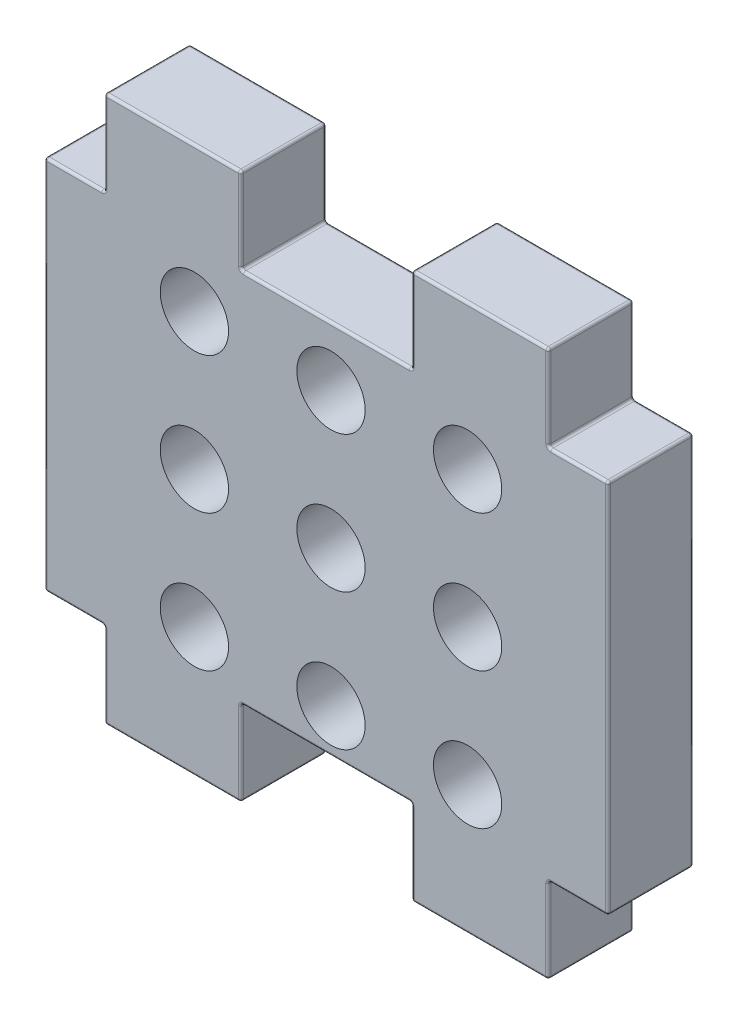
from build123d import *

# Parameters (mm, degrees)
SZKIC1_R                    = 2
SZKIC1_W                    = 8
SZKIC1_H                    = 5
DODANIE_WYCI_GNI_CIE1_DEPTH = 2.5
ZAOKR_GLENIE1_R             = 0.15


with BuildPart() as part:
    # Szkic1 → Dodanie-wyciągnięcie1 (new body, symmetric)
    with BuildSketch(Plane.XY):
        Polygon((-13, 11), (-16.5, 11), (-16.5, -11), (-13, -11), (-5, -11), (5, -11), (13, -11), (16.5, -11), (16.5, 11), (13, 11), (5, 11), (-5, 11), align=None)
        with Locations((-7.726006327, -8.444050887)):
            Circle(SZKIC1_R, mode=Mode.SUBTRACT)
        with Locations((-7.726006327, -0.444050887)):
            Circle(SZKIC1_R, mode=Mode.SUBTRACT)
        with Locations((0.273993673, -8.444050887)):
            Circle(SZKIC1_R, mode=Mode.SUBTRACT)
        with Locations((8.273993673, -8.444050887)):
            Circle(SZKIC1_R, mode=Mode.SUBTRACT)
        with Locations((0.273993673, -0.444050887)):
            Circle(SZKIC1_R, mode=Mode.SUBTRACT)
        with Locations((8.273993673, -0.444050887)):
            Circle(SZKIC1_R, mode=Mode.SUBTRACT)
        with Locations((-7.726006327, 7.555949113)):
            Circle(SZKIC1_R, mode=Mode.SUBTRACT)
        with Locations((0.273993673, 7.555949113)):
            Circle(SZKIC1_R, mode=Mode.SUBTRACT)
        with Locations((8.273993673, 7.555949113)):
            Circle(SZKIC1_R, mode=Mode.SUBTRACT)
        with Locations((-9, -13.5)):
            Rectangle(SZKIC1_W, SZKIC1_H)
        with Locations((9, -13.5)):
            Rectangle(SZKIC1_W, SZKIC1_H)
        with Locations((9, 13.5)):
            Rectangle(SZKIC1_W, SZKIC1_H)
        with Locations((-9, 13.5)):
            Rectangle(SZKIC1_W, SZKIC1_H)
    extrude(amount=DODANIE_WYCI_GNI_CIE1_DEPTH, both=True)

    # Zaokrąglenie1
    zaokr_glenie1_edges = [part.edges().sort_by_distance(p)[0] for p in [
        (-14.75, 11, 2.5),
        (-16.5, 0, 2.5),
        (-14.75, 11, -2.5),
        (-13, 13.5, -2.5),
        (-9, 16, -2.5),
        (-14.75, -11, 2.5),
        (-5, 13.5, -2.5),
        (0, 11, -2.5),
        (5, 13.5, -2.5),
        (9, 16, -2.5),
        (13, 13.5, -2.5),
        (14.75, 11, -2.5),
        (16.5, 0, -2.5),
        (14.75, -11, -2.5),
        (-13, -13.5, 2.5),
        (13, -13.5, -2.5),
        (9, -16, -2.5),
        (5, -13.5, -2.5),
        (0, -11, -2.5),
        (-5, -13.5, -2.5),
        (-9, -16, -2.5),
        (-13, -13.5, -2.5),
        (-14.75, -11, -2.5),
        (-9, -16, 2.5),
        (-16.5, 0, -2.5),
        (-5, -13.5, 2.5),
        (0, -11, 2.5),
        (-16.5, 11, 0),
        (-13, 11, 0),
        (-13, 16, 0),
        (-5, 16, 0),
        (-5, 11, 0),
        (5, 11, 0),
        (5, 16, 0),
        (13, 16, 0),
        (13, 11, 0),
        (16.5, 11, 0),
        (16.5, -11, 0),
        (13, -11, 0),
        (13, -16, 0),
        (5, -16, 0),
        (5, -11, 0),
        (-5, -11, 0),
        (-5, -16, 0),
        (-13, -16, 0),
        (-13, -11, 0),
        (5, -13.5, 2.5),
        (-16.5, -11, 0),
        (9, -16, 2.5),
        (13, -13.5, 2.5),
        (14.75, -11, 2.5),
        (16.5, 0, 2.5),
        (14.75, 11, 2.5),
        (13, 13.5, 2.5),
        (9, 16, 2.5),
        (5, 13.5, 2.5),
        (0, 11, 2.5),
        (-5, 13.5, 2.5),
        (-9, 16, 2.5),
        (-13, 13.5, 2.5),
    ]]
    fillet(zaokr_glenie1_edges, radius=ZAOKR_GLENIE1_R)


solid = part.part
